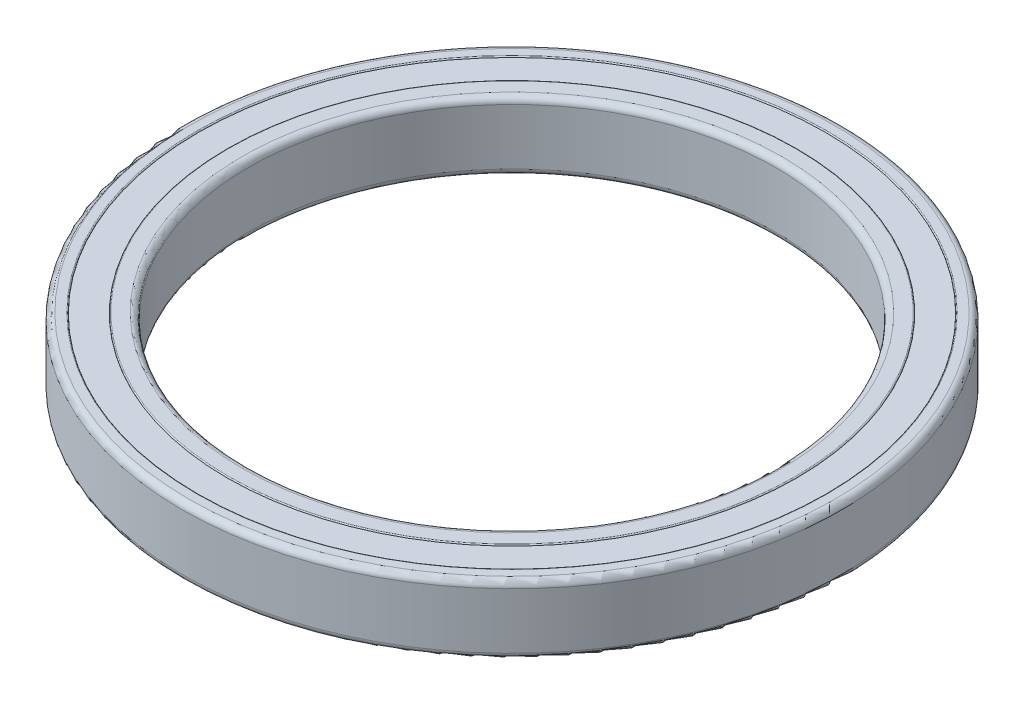
from build123d import *

# Parameters (mm, degrees)
SKIZZE1_R       = 62.5
SKIZZE1_R_2     = 59.5
AU_ENRING_DEPTH = 6.5
SKIZZE2_R       = 54
SKIZZE2_R_2     = 50
INNENRING_DEPTH = 6.5
VERRUNDUNG1_R   = 1.2
VERRUNDUNG2_R   = 1.2
VERRUNDUNG3_R   = 0.2
VERRUNDUNG4_R   = 0.2
SKIZZE3_R       = 59.5
SKIZZE3_R_2     = 54
DICHTUNG_DEPTH  = 6.3


with BuildPart() as part:
    # Skizze1 → Außenring (new body, symmetric)
    with BuildSketch(Plane(origin=(0, 0, 0), x_dir=(1, 0, 0), z_dir=(0, 1, 0))):
        Circle(SKIZZE1_R)
        Circle(SKIZZE1_R_2, mode=Mode.SUBTRACT)
    extrude(amount=AU_ENRING_DEPTH, both=True)

    # Verrundung1
    verrundung1_edges = [part.edges().sort_by_distance(p)[0] for p in [
        (-62.5, -6.5, 0),
        (-62.5, 6.5, 0),
    ]]
    fillet(verrundung1_edges, radius=VERRUNDUNG1_R)

    # Verrundung4
    verrundung4_edges = [part.edges().sort_by_distance(p)[0] for p in [
        (-59.5, -6.5, 0),
        (-59.5, 6.5, 0),
    ]]
    fillet(verrundung4_edges, radius=VERRUNDUNG4_R)


with BuildPart() as body_2:
    # Skizze2 → Innenring (new body, symmetric)
    with BuildSketch(Plane(origin=(0, 0, 0), x_dir=(1, 0, 0), z_dir=(0, 1, 0))):
        Circle(SKIZZE2_R)
        Circle(SKIZZE2_R_2, mode=Mode.SUBTRACT)
    extrude(amount=INNENRING_DEPTH, both=True)

    # Verrundung2
    verrundung2_edges = [body_2.edges().sort_by_distance(p)[0] for p in [
        (-50, -6.5, 0),
        (-50, 6.5, 0),
    ]]
    fillet(verrundung2_edges, radius=VERRUNDUNG2_R)

    # Verrundung3
    verrundung3_edges = [body_2.edges().sort_by_distance(p)[0] for p in [
        (-54, -6.5, 0),
        (-54, 6.5, 0),
    ]]
    fillet(verrundung3_edges, radius=VERRUNDUNG3_R)


with BuildPart() as body_3:
    # Skizze3 → Dichtung (new body, symmetric)
    with BuildSketch(Plane(origin=(0, 0, 0), x_dir=(1, 0, 0), z_dir=(0, 1, 0))):
        Circle(SKIZZE3_R)
        Circle(SKIZZE3_R_2, mode=Mode.SUBTRACT)
    extrude(amount=DICHTUNG_DEPTH, both=True)


solid = Compound([part.part, body_2.part, body_3.part])
